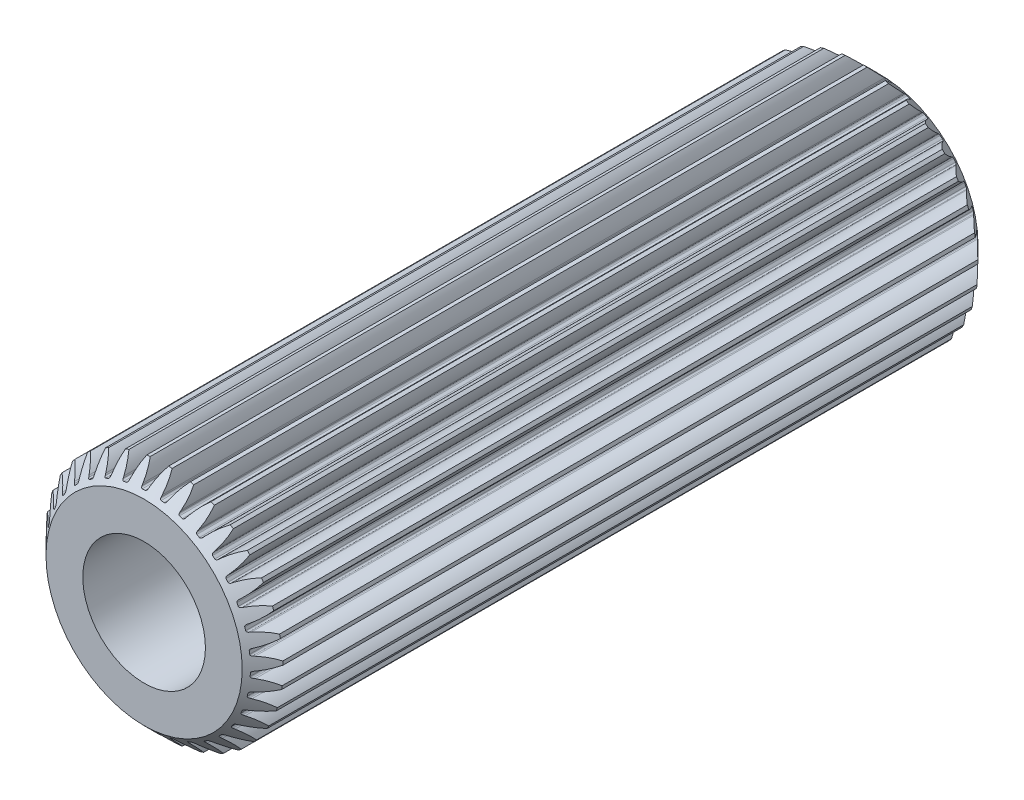
from build123d import *

# Parameters (mm, degrees)
SCHIZZO3_R                   = 2.9
ESTRUSIONE_ESTRUSIONE2_DEPTH = 18
SMUSSO2_SIZE                 = 0.5
TAGLIO_ESTRUSIONE1_DEPTH     = 18
RIPETIZIONECIRCOLARE1_COUNT  = 34
SCHIZZO6_R                   = 1.5
TAGLIO_ESTRUSIONE2_DEPTH     = 9


with BuildPart() as part:
    # Schizzo3 → Estrusione-Estrusione2 (new body)
    with BuildSketch(Plane.XY):
        Circle(SCHIZZO3_R)
    extrude(amount=ESTRUSIONE_ESTRUSIONE2_DEPTH)

    # Smusso2
    smusso2_edges = [part.edges().sort_by_distance(p)[0] for p in [
        (-2.9, 0, 0),
        (-2.9, 0, 18),
    ]]
    chamfer(smusso2_edges, length=SMUSSO2_SIZE)

    # Schizzo4 → Taglio-Estrusione1 (cut)
    with BuildSketch(Plane.XY.offset(18)):
        with BuildLine():
            Line((2.564629538, -0.043592798), (2.531845552, -0.04908666))
            ThreePointArc((2.531845552, -0.04908666), (2.508379306, -0.06216682), (2.498480782, -0.087142297))
            ThreePointArc((2.498480782, -0.087142297), (2.496988641, -0.122669186), (2.494991353, -0.158171258))
            ThreePointArc((2.494991353, -0.158171258), (2.502394188, -0.183996697), (2.524465357, -0.199313966))
            Line((2.524465357, -0.199313966), (2.556552987, -0.207994767))
            ThreePointArc((2.556552987, -0.207994767), (2.724312128, -0.271208362), (2.87689813, -0.365317873))
            ThreePointArc((2.87689813, -0.365317873), (2.896506823, -0.142296256), (2.898852493, 0.081573439))
            ThreePointArc((2.898852493, 0.081573439), (2.737776889, 0.002873135), (2.564629538, -0.043592798))
        make_face()
    taglio_estrusione1 = extrude(amount=-TAGLIO_ESTRUSIONE1_DEPTH, mode=Mode.SUBTRACT)

    # RipetizioneCircolare1: Taglio-Estrusione1 ×34 about axis
    ripetizionecircolare1_axis = Axis((0, 0, 0), (0, 0, 1))
    for i in range(1, RIPETIZIONECIRCOLARE1_COUNT):
        add(taglio_estrusione1.rotate(ripetizionecircolare1_axis, i * 360 / RIPETIZIONECIRCOLARE1_COUNT), mode=Mode.SUBTRACT)

    # Schizzo6 → Taglio-Estrusione2 (cut)
    with BuildSketch(Plane.XY.offset(18)):
        Circle(SCHIZZO6_R)
    extrude(amount=-TAGLIO_ESTRUSIONE2_DEPTH, mode=Mode.SUBTRACT)


solid = part.part
